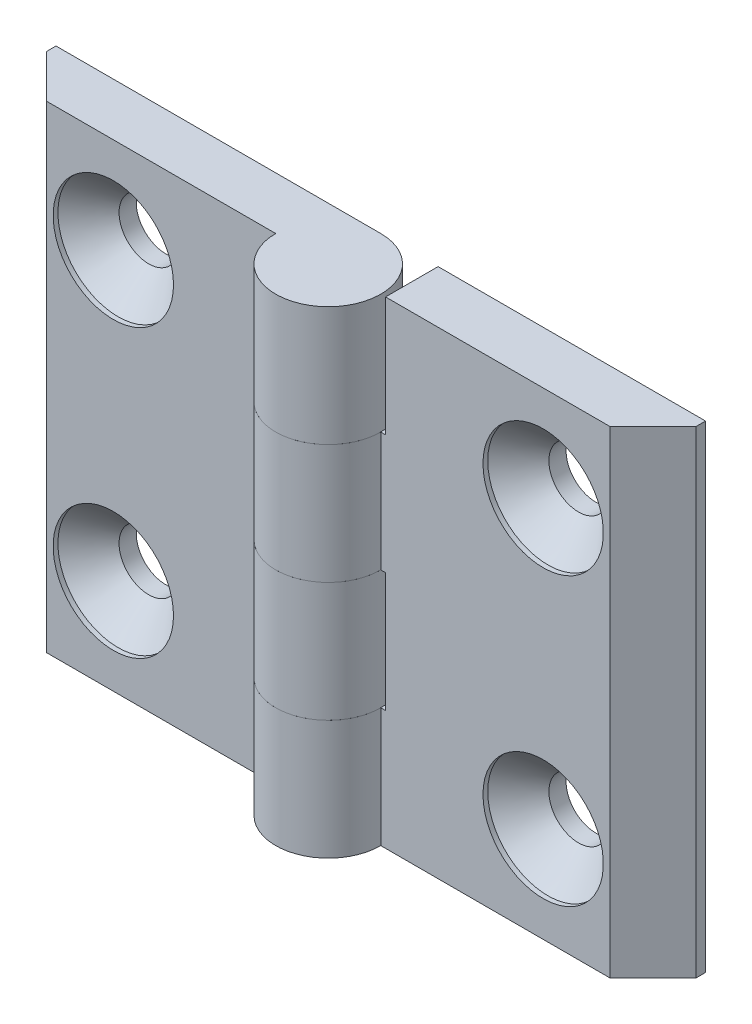
from build123d import *

# Parameters (mm, degrees)
EXTRUDE_1_DEPTH            = 25
SKETCH_3_W                 = 11.5
SKETCH_3_H                 = 12.5
CUT_EXTRUDE_1_DEPTH        = 6.5
CUT_EXTRUDE_1_DEPTH_BACK   = 6.5
HOLE_WIZARD_M61_AT_2_COUNT = 2
HOLE_WIZARD_M61_AT_2_PITCH = 30
PATTERN_CIRCULAR_1_COUNT   = 2


with BuildPart() as part:
    # Эскиз1 → Бобышка-Вытянуть1 (new body, symmetric)
    with BuildSketch(Plane(origin=(0, 0, 0), x_dir=(1, 0, 0), z_dir=(0, 1, 0))):
        with BuildLine():
            Line((0, 5.5), (-34, 5.5))
            Line((-34, 5.5), (-34, 4.5))
            Line((-34, 4.5), (-29.5, 0))
            Line((-29.5, 0), (-5.5, 0))
            ThreePointArc((-5.5, 0), (3.889087297, -3.889087297), (0, 5.5))
        make_face()
    extrude(amount=EXTRUDE_1_DEPTH, both=True)

    # Эскиз3 → Вырез-Вытянуть1 (cut, two sides)
    with BuildSketch(Plane.XY) as cut_extrude_1_sk:
        with Locations((-0.25, 6.25)):
            Rectangle(SKETCH_3_W, SKETCH_3_H)
        with Locations((-0.25, -18.75)):
            Rectangle(SKETCH_3_W, SKETCH_3_H)
    extrude(amount=CUT_EXTRUDE_1_DEPTH, mode=Mode.SUBTRACT)
    extrude(cut_extrude_1_sk.sketch, amount=-CUT_EXTRUDE_1_DEPTH_BACK, mode=Mode.SUBTRACT)

    # Эскиз6 → Зенковка для винта с полупотайной головкой M61 (revolve, cut)
    with BuildSketch(Plane(origin=(-22.5, 15, 0), x_dir=(0, -1, 0), z_dir=(1, 0, 0))):
        Polygon((0, 0), (0, 5.5), (3.1, 5.5), (3.1, 3.7), (6.3, 0.5), (6.3, 0), align=None)
    hole_wizard_m61 = revolve(axis=Axis((-22.5, 15, 6.35), (0, 0, -1)), mode=Mode.SUBTRACT)

    # Зенковка для винта с полупотайной головкой M61 at 2: Зенковка для винта с полупотайной головкой M61 ×2
    with Locations(*[(0, -i * HOLE_WIZARD_M61_AT_2_PITCH, 0) for i in range(1, HOLE_WIZARD_M61_AT_2_COUNT)]):
        add(hole_wizard_m61, mode=Mode.SUBTRACT)


with BuildPart() as pattern_circular_1_1:
    # Круговой массив1: pattern copy
    add(part.part.rotate(Axis((0, 0, 0), (0, 0, 1)), 1 * 360 / PATTERN_CIRCULAR_1_COUNT))


solid = Compound([part.part, pattern_circular_1_1.part])
